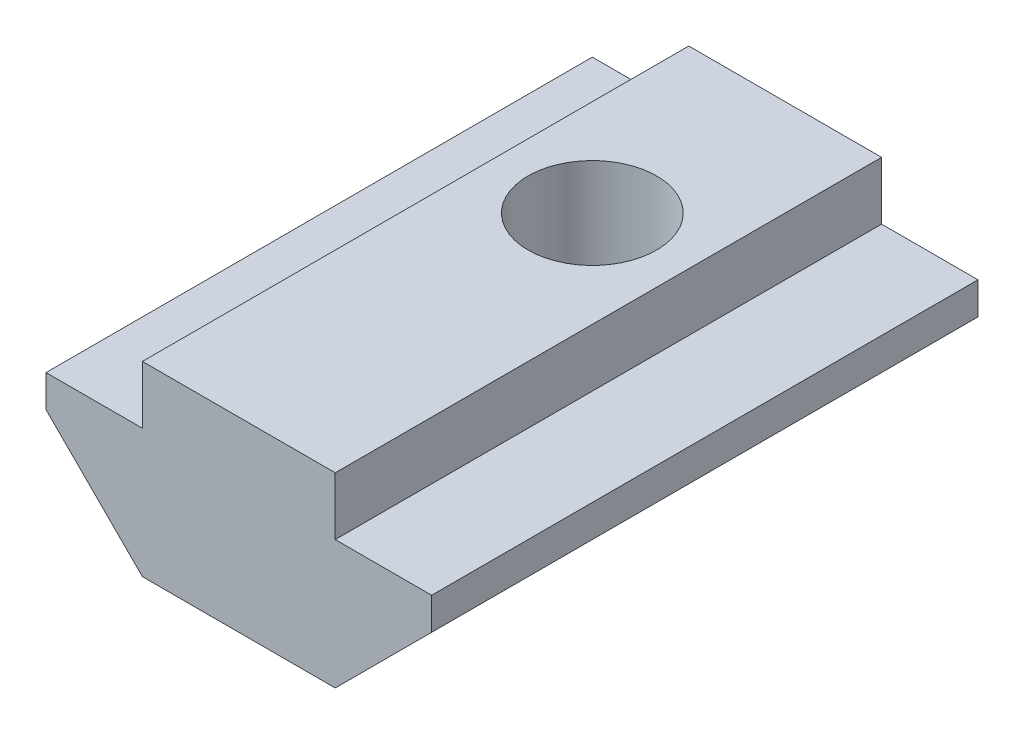
from build123d import *

# Parameters (mm, degrees)
ESTRUSIONE_ESTRUSIONE1_DEPTH = 17
SCHIZZO2_R                   = 2
TAGLIO_ESTRUSIONE1_DEPTH     = 6.8


with BuildPart() as part:
    # Schizzo1 → Estrusione-Estrusione1 (new body)
    with BuildSketch(Plane.XY):
        Polygon((3, 0), (-3, 0), (-6, 3), (-6, 4), (-3, 4), (-3, 5.8), (3, 5.8), (3, 4), (6, 4), (6, 3), align=None)
    extrude(amount=ESTRUSIONE_ESTRUSIONE1_DEPTH)

    # Schizzo2 → Taglio-Estrusione1 (cut, through all)
    with BuildSketch(Plane(origin=(0, 5.8, 0), x_dir=(1, 0, 0), z_dir=(0, 1, 0))):
        with Locations((0, -6)):
            Circle(SCHIZZO2_R)
    extrude(amount=-TAGLIO_ESTRUSIONE1_DEPTH, mode=Mode.SUBTRACT)

    # Schizzo4 → Rivoluzione2 (revolve)
    with BuildSketch(Plane(origin=(0, 0, 0), x_dir=(0, 0, -1), z_dir=(1, 0, 0))):
        with BuildLine():
            Line((-12, -1.5), (-12, 0))
            Line((-12, 0), (-13.5, 0))
            ThreePointArc((-13.5, 0), (-13.060660172, -1.060660172), (-12, -1.5))
        make_face()
    revolve(axis=Axis((0, 0, 12), (0, -1, 0)))


solid = part.part
